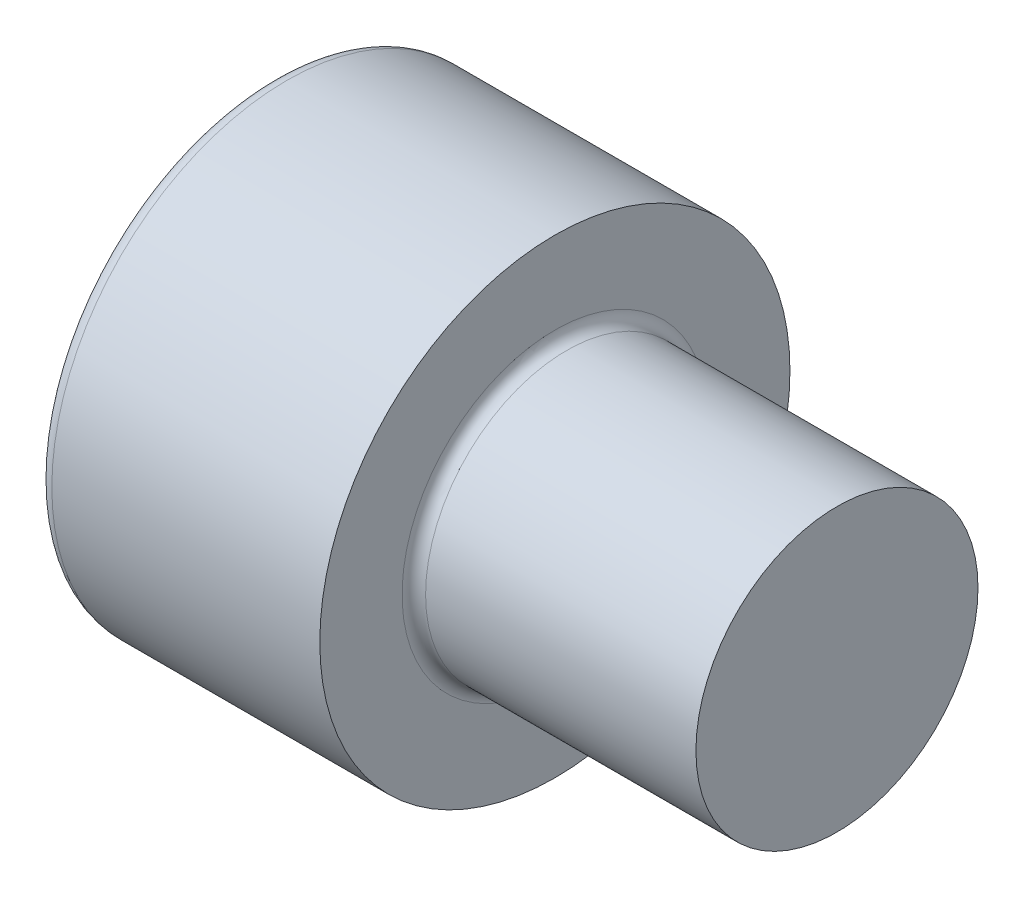
from build123d import *

# Parameters (mm, degrees)
FILLET1_R          = 0.25
FILLET2_R          = 0.3
HEX_2_DEPTH        = 3
SKETCH4_R          = 7.875730731
CUT_EXTRUDE1_DEPTH = 4


with BuildPart() as part:
    # BodySke → Base-Revolve (revolve)
    with BuildSketch(Plane.XY):
        Polygon((0, 0), (0, 5), (6, 5), (6, 3), (15.4455, 3), (16, 2.4455), (16, 0), align=None)
    revolve(axis=Axis((-31.75, 0, 0), (1, 0, 0)))

    # Fillet1
    fillet1_edges = [part.edges().sort_by_distance(p)[0] for p in [
        (6, -3, 0),
    ]]
    fillet(fillet1_edges, radius=FILLET1_R)

    # Fillet2
    fillet2_edges = [part.edges().sort_by_distance(p)[0] for p in [
        (0, -5, 0),
    ]]
    fillet(fillet2_edges, radius=FILLET2_R)

    # Sketch2 → Hex-PreBroach (revolve, cut)
    with BuildSketch(Plane.XY):
        Polygon((0, 2.542), (3, 2.542), (4.467624384, 0), (0, 0), align=None)
    revolve(axis=Axis((0, 0, 0), (1, 0, 0)), mode=Mode.SUBTRACT)

    # Sketch3 → Hex 2 (cut)
    with BuildSketch(Plane(origin=(0, 0, 0), x_dir=(0, 0.5, 0.866025404), z_dir=(-1, 0, 0))):
        Polygon((1.467624384, 2.542), (-1.467624384, 2.542), (-2.935248769, 0), (-1.467624384, -2.542), (1.467624384, -2.542), (2.935248769, 0), align=None)
    extrude(amount=-HEX_2_DEPTH, mode=Mode.SUBTRACT)

    # Sketch4 → Cut-Extrude1 (cut)
    with BuildSketch(Plane(origin=(16, 0, 0), x_dir=(0, 0, -1), z_dir=(1, 0, 0))):
        Circle(SKETCH4_R)
    extrude(amount=-CUT_EXTRUDE1_DEPTH, mode=Mode.SUBTRACT)


solid = part.part
